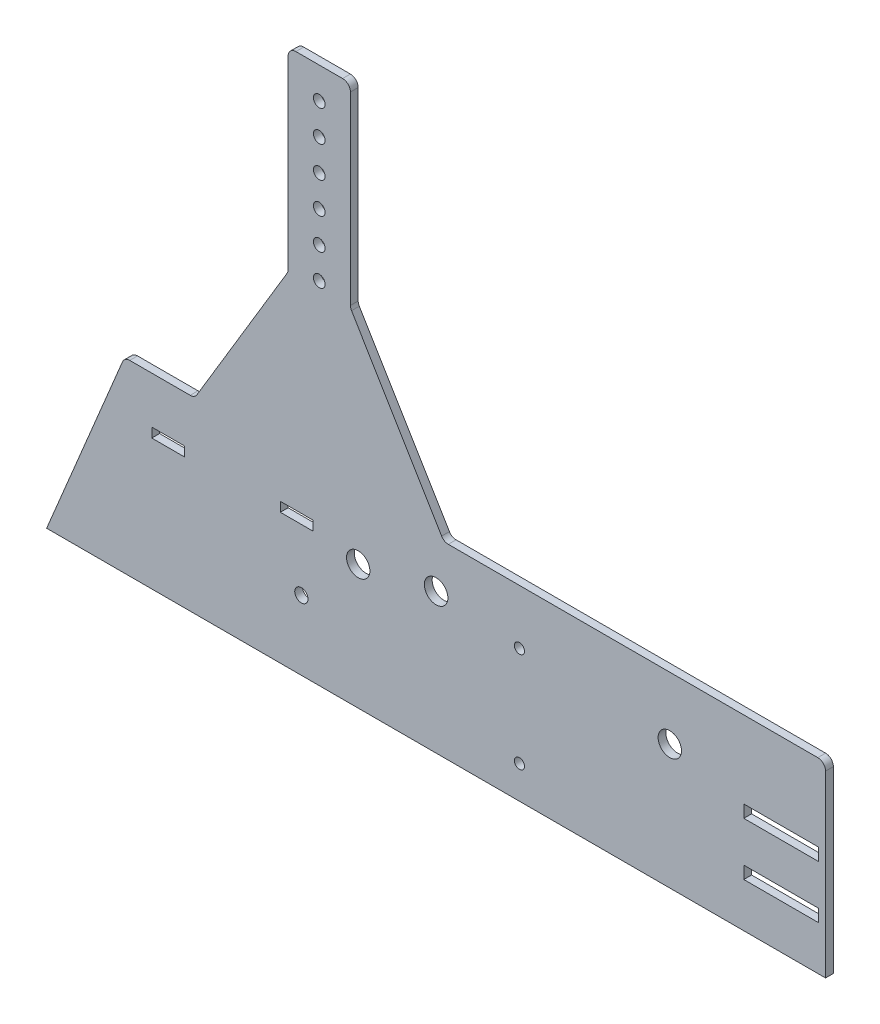
from build123d import *

# Parameters (mm, degrees)
ESQUISSE1_R        = 15
ESQUISSE1_R_2      = 6.5
ESQUISSE1_R_3      = 8.5
ESQUISSE1_R_4      = 15.1
ESQUISSE1_R_5      = 7.5
ESQUISSE1_W        = 96
ESQUISSE1_H        = 16
ESQUISSE1_W_2      = 42
ESQUISSE1_H_2      = 12.2
BOSS_EXTRU_1_DEPTH = 10
CONG_1_R           = 10


with BuildPart() as part:
    # Esquisse1 → Boss.-Extru.1 (new body)
    with BuildSketch(Plane.XY):
        Polygon((0, 0), (-1000, 0), (-900, 240), (-810, 240), (-690, 440), (-690, 690), (-610, 690), (-610, 440), (-490, 240), (0, 240), align=None)
        with Locations((-200, 160)):
            Circle(ESQUISSE1_R, mode=Mode.SUBTRACT)
        with Locations((-600, 160)):
            Circle(ESQUISSE1_R, mode=Mode.SUBTRACT)
        with Locations((-393, 170)):
            Circle(ESQUISSE1_R_2, mode=Mode.SUBTRACT)
        with Locations((-393, 42)):
            Circle(ESQUISSE1_R_2, mode=Mode.SUBTRACT)
        with Locations((-673, 89)):
            Circle(ESQUISSE1_R_3, mode=Mode.SUBTRACT)
        with Locations((-500, 180)):
            Circle(ESQUISSE1_R_4, mode=Mode.SUBTRACT)
        with Locations((-650, 650)):
            Circle(ESQUISSE1_R_5, mode=Mode.SUBTRACT)
        with Locations((-650, 610)):
            Circle(ESQUISSE1_R_5, mode=Mode.SUBTRACT)
        with Locations((-650, 570)):
            Circle(ESQUISSE1_R_5, mode=Mode.SUBTRACT)
        with Locations((-650, 530)):
            Circle(ESQUISSE1_R_5, mode=Mode.SUBTRACT)
        with Locations((-650, 490)):
            Circle(ESQUISSE1_R_5, mode=Mode.SUBTRACT)
        with Locations((-650, 450)):
            Circle(ESQUISSE1_R_5, mode=Mode.SUBTRACT)
        with Locations((-57, 133)):
            Rectangle(ESQUISSE1_W, ESQUISSE1_H, mode=Mode.SUBTRACT)
        with Locations((-57, 65)):
            Rectangle(ESQUISSE1_W, ESQUISSE1_H, mode=Mode.SUBTRACT)
        with Locations((-844, 173.9)):
            Rectangle(ESQUISSE1_W_2, ESQUISSE1_H_2, mode=Mode.SUBTRACT)
        with Locations((-679, 173.9)):
            Rectangle(ESQUISSE1_W_2, ESQUISSE1_H_2, mode=Mode.SUBTRACT)
    extrude(amount=BOSS_EXTRU_1_DEPTH)

    # Congé1
    cong_1_edges = [part.edges().sort_by_distance(p)[0] for p in [
        (-900, 240, 5),
        (-810, 240, 5),
        (-690, 440, 5),
        (-690, 690, 5),
        (-610, 690, 5),
        (-610, 440, 5),
        (-490, 240, 5),
        (0, 240, 5),
    ]]
    fillet(cong_1_edges, radius=CONG_1_R)


solid = part.part
